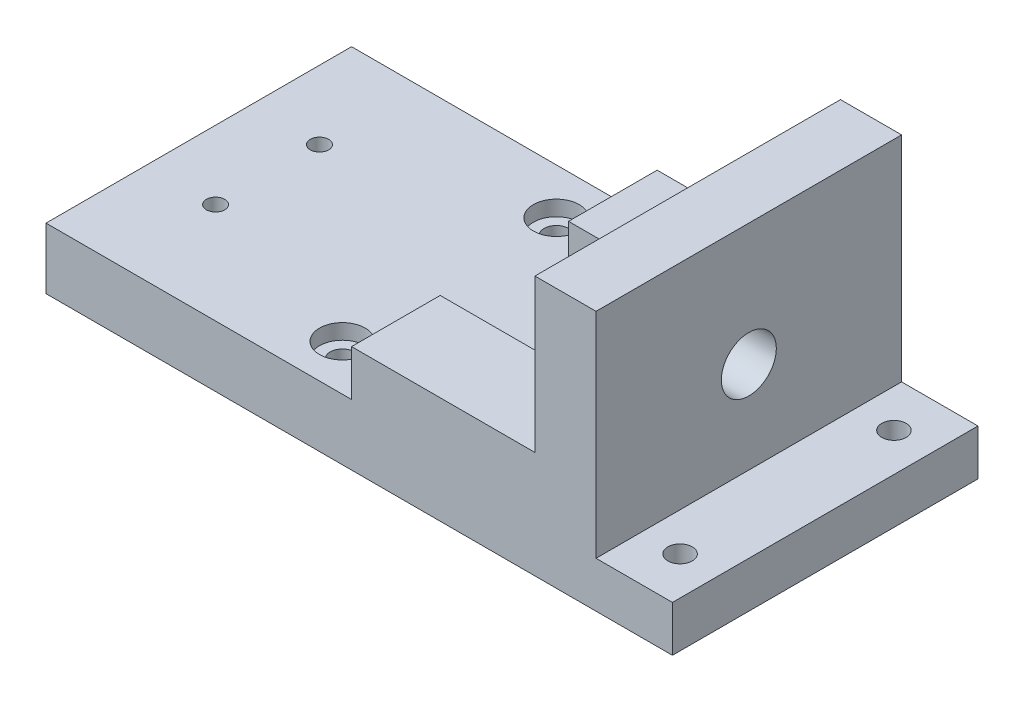
from build123d import *

# Parameters (mm, degrees)
BOSS_EXTRUDE1_DEPTH     = 50
SKETCH2_R               = 9
CUT_EXTRUDE1_DEPTH      = 26
CUT_EXTRUDE1_DEPTH_BACK = 181
SKETCH3_W               = 60
SKETCH3_H               = 42
CUT_EXTRUDE2_DEPTH      = 15
SKETCH4_R               = 3
SKETCH4_R_2             = 4
CUT_EXTRUDE3_DEPTH      = 21
SKETCH4_3_R             = 7.5
CUT_EXTRUDE4_DEPTH      = 5


with BuildPart() as part:
    # Sketch1 → Boss-Extrude1 (new body, symmetric)
    with BuildSketch(Plane.XY):
        Polygon((0, 0), (0, 15), (-25, 15), (-25, 85), (-45, 85), (-45, 35), (-105, 35), (-105, 20), (-205, 20), (-205, 0), align=None)
    extrude(amount=BOSS_EXTRUDE1_DEPTH, both=True)

    # Sketch2 → Cut-Extrude1 (cut, two sides)
    with BuildSketch(Plane(origin=(-25, 0, 0), x_dir=(0, 0, -1), z_dir=(1, 0, 0))) as cut_extrude1_sk:
        with Locations((0, 45)):
            Circle(SKETCH2_R)
    extrude(amount=CUT_EXTRUDE1_DEPTH, mode=Mode.SUBTRACT)
    extrude(cut_extrude1_sk.sketch, amount=-CUT_EXTRUDE1_DEPTH_BACK, mode=Mode.SUBTRACT)

    # Sketch3 → Cut-Extrude2 (cut)
    with BuildSketch(Plane(origin=(0, 35, 0), x_dir=(1, 0, 0), z_dir=(0, 1, 0))):
        with Locations((-75, 0)):
            Rectangle(SKETCH3_W, SKETCH3_H)
    extrude(amount=-CUT_EXTRUDE2_DEPTH, mode=Mode.SUBTRACT)

    # Sketch4 → Cut-Extrude3 (cut, through all)
    with BuildSketch(Plane(origin=(0, 20, 0), x_dir=(1, 0, 0), z_dir=(0, 1, 0))):
        with Locations((-182.5, 17)):
            Circle(SKETCH4_R)
        with Locations((-123, 35)):
            Circle(SKETCH4_R_2)
        with Locations((-12.5, 35)):
            Circle(SKETCH4_R_2)
        with Locations((-12.5, -35)):
            Circle(SKETCH4_R_2)
        with Locations((-123, -35)):
            Circle(SKETCH4_R_2)
        with Locations((-182.5, -17)):
            Circle(SKETCH4_R)
    extrude(amount=-CUT_EXTRUDE3_DEPTH, mode=Mode.SUBTRACT)

    # Sketch4_3 → Cut-Extrude4 (cut)
    with BuildSketch(Plane(origin=(0, 20, 0), x_dir=(1, 0, 0), z_dir=(0, 1, 0))):
        with Locations((-123, 35)):
            Circle(SKETCH4_3_R)
        with Locations((-12.5, 35)):
            Circle(SKETCH4_3_R)
        with Locations((-12.5, -35)):
            Circle(SKETCH4_3_R)
        with Locations((-123, -35)):
            Circle(SKETCH4_3_R)
    extrude(amount=-CUT_EXTRUDE4_DEPTH, mode=Mode.SUBTRACT)


solid = part.part
